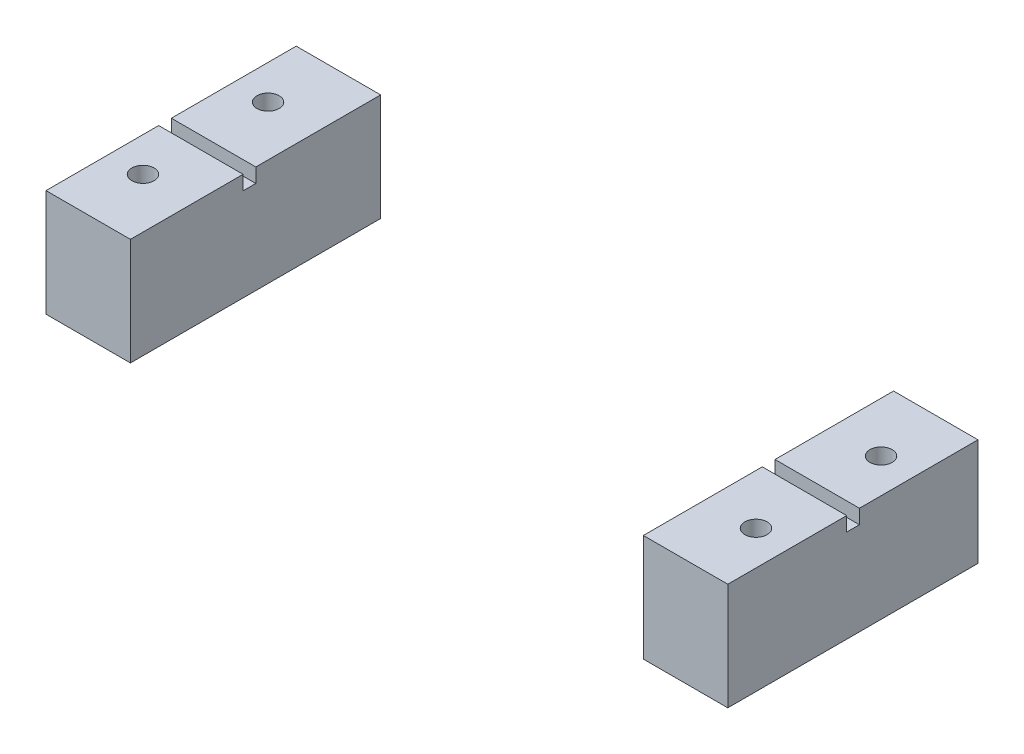
from build123d import *

# Parameters (mm, degrees)
SKETCH1_W             = 6.75
SKETCH1_H             = 20
SKETCH1_R             = 0.889
BOSS_EXTRUDE1_DEPTH   = 8.5598
BOSS_EXTRUDE1_2_DEPTH = 8.5598
SKETCH2_W             = 6.75
SKETCH2_H             = 1.016
CUT_EXTRUDE1_DEPTH    = 1.143


with BuildPart() as part:
    # Sketch1 → Boss-Extrude1 (new body)
    with BuildSketch(Plane(origin=(0, 0, 0), x_dir=(1, 0, 0), z_dir=(0, 1, 0))):
        with Locations((3.375, 10)):
            Rectangle(SKETCH1_W, SKETCH1_H)
        with Locations((2.75, 15)):
            Circle(SKETCH1_R, mode=Mode.SUBTRACT)
        with Locations((2.75, 5)):
            Circle(SKETCH1_R, mode=Mode.SUBTRACT)
    extrude(amount=BOSS_EXTRUDE1_DEPTH)


with BuildPart() as body_2:
    # Sketch1 → Boss-Extrude1 2 (new body)
    with BuildSketch(Plane(origin=(0, 0, 0), x_dir=(1, 0, 0), z_dir=(0, 1, 0))):
        with Locations((51.125, 10)):
            Rectangle(SKETCH1_W, SKETCH1_H)
        with Locations((51.75, 15)):
            Circle(SKETCH1_R, mode=Mode.SUBTRACT)
        with Locations((51.75, 5)):
            Circle(SKETCH1_R, mode=Mode.SUBTRACT)
    extrude(amount=BOSS_EXTRUDE1_2_DEPTH)


with BuildPart() as cut_extrude1_tool:
    # Sketch2 → Cut-Extrude1 (new body)
    with BuildSketch(Plane(origin=(0, 8.5598, 0), x_dir=(1, 0, 0), z_dir=(0, 1, 0))):
        with Locations((3.375, 9.513485429)):
            Rectangle(SKETCH2_W, SKETCH2_H)
        with Locations((51.125, 10.013485429)):
            Rectangle(SKETCH2_W, SKETCH2_H)
    extrude(amount=-CUT_EXTRUDE1_DEPTH)


with BuildPart() as part_1:
    add(part.part)

    # Cut-Extrude1: cut by cut_extrude1_tool
    add(cut_extrude1_tool.part, mode=Mode.SUBTRACT)


with BuildPart() as body_2_1:
    add(body_2.part)

    # Cut-Extrude1: cut by cut_extrude1_tool
    add(cut_extrude1_tool.part, mode=Mode.SUBTRACT)


solid = Compound([part_1.part, body_2_1.part])
